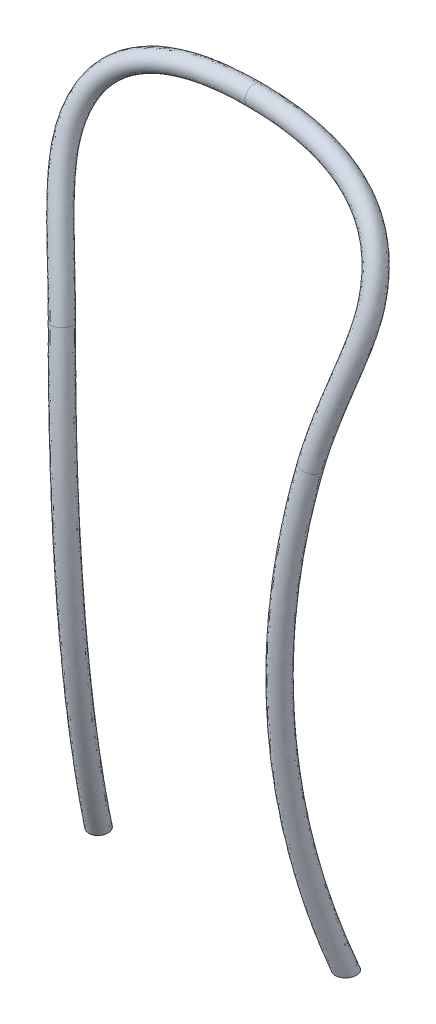
from build123d import *

# Parameters (mm, degrees)
SKETCH5_R          = 12.5
SKETCH7_W          = 45.417873618
SKETCH7_H          = 37.777483663
CUT_EXTRUDE5_DEPTH = 208.499943078


with BuildPart() as part:
    # Sweep1: sweep along a curve in space
    with BuildLine() as sweep1_path:
        add(Edge.make_bspline(
            [(160, 0, 0), (152.168995858, 47.136323017, 16.166816632), (146.122450099, 95.120491892, 29.356217031), (139.952677427, 168.392961736, 44.660373104), (138.379961392, 193.03371775, 49.012849734), (136.780978785, 230.328191237, 54.395481508), (136.37436891, 242.833069839, 56.000462856), (135.822706907, 267.872759039, 58.813331371), (135.677891412, 280.37835954, 60.018567231), (135.603978598, 342.835886206, 65.054575905), (137.621923304, 392.576924024, 65.926580289), (145.742929319, 491.619153335, 61.565817581), (151.846136765, 540.920325886, 56.332706031), (160, 590, 48.007453769)],
            knots=[0, 0, 0, 0, 0.25, 0.25, 0.375, 0.375, 0.4375, 0.4375, 0.5, 0.5, 0.75, 0.75, 1, 1, 1, 1], degree=3))
        add(Edge.make_bspline(
            [(160, 590, 48.007453769), (162.981702179, 607.947440007, 44.963078104), (166.964825907, 625.641620983, 41.542854917), (175.62262971, 660.671035207, 33.961330592), (180.330277173, 678.008574201, 29.801006101), (186.748757957, 703.99774957, 22.94669027), (188.778264083, 712.658436341, 20.559101777), (192.239308402, 730.050475484, 15.551190002), (193.687712952, 738.778495637, 12.932203268), (194.829481965, 752.038732011, 8.78361736), (195.027423111, 756.498046944, 7.360004127), (194.966303397, 765.314904889, 4.488636581), (194.708623744, 769.691324574, 3.035119915), (193.735398914, 778.380323579, 0.094173157), (193.031889874, 782.694133553, -1.393688189), (191.120070519, 791.253656053, -4.40004091), (189.897048786, 795.528945936, -5.929481967), (185.429488794, 807.931894174, -10.442853074), (181.395522298, 815.674881246, -13.363499866), (173.584929947, 826.437147399, -17.533329967), (170.672441216, 829.889454724, -18.891169484), (164.484137305, 836.27240368, -21.431723138), (161.186405815, 839.238231238, -22.627920695), (154.225811565, 844.768033136, -24.880413561), (150.562893349, 847.331937836, -25.936708819), (142.906849571, 852.098638067, -27.917094529), (138.891445295, 854.31154694, -28.845500546), (126.588774607, 860.368532638, -31.404509395), (118.057357002, 863.649563386, -32.815297533), (100.519799658, 869.130740409, -35.190162305), (91.488015333, 871.327217868, -36.153340488), (73.41365963, 874.839659479, -37.700659365), (64.323248623, 876.170692829, -38.291638266), (36.932915892, 879.216438218, -39.646985762), (18.515889379, 880, -40), (0, 880, -40)],
            knots=[0, 0, 0, 0, 0.125, 0.125, 0.25, 0.25, 0.3125, 0.3125, 0.375, 0.375, 0.40625, 0.40625, 0.4375, 0.4375, 0.46875, 0.46875, 0.5, 0.5, 0.5625, 0.5625, 0.59375, 0.59375, 0.625, 0.625, 0.65625, 0.65625, 0.6875, 0.6875, 0.75, 0.75, 0.8125, 0.8125, 0.875, 0.875, 1, 1, 1, 1], degree=3))
    # Sketch5 → Sweep1 (sweep)
    with BuildSketch(Plane(origin=(0, 0, 0), x_dir=(0, 0, -1), z_dir=(1, 0, 0))):
        with Locations((40, 880)):
            Circle(SKETCH5_R)
    sweep(path=sweep1_path.line)

    # Sketch7 → Cut-Extrude5 (cut, through all)
    with BuildSketch(Plane(origin=(0, 0, 0), x_dir=(0, 0, -1), z_dir=(1, 0, 0))):
        with Locations((0, -14.437307972)):
            Rectangle(SKETCH7_W, SKETCH7_H)
    extrude(amount=CUT_EXTRUDE5_DEPTH, mode=Mode.SUBTRACT)

    # Mirror1: part across plane


with BuildPart() as part_1:
    add(part.part)
    add(part.part.mirror(Plane(origin=(0, 880, -40), x_dir=(0, 0, 1), z_dir=(1, 0, 0))))


solid = part_1.part
